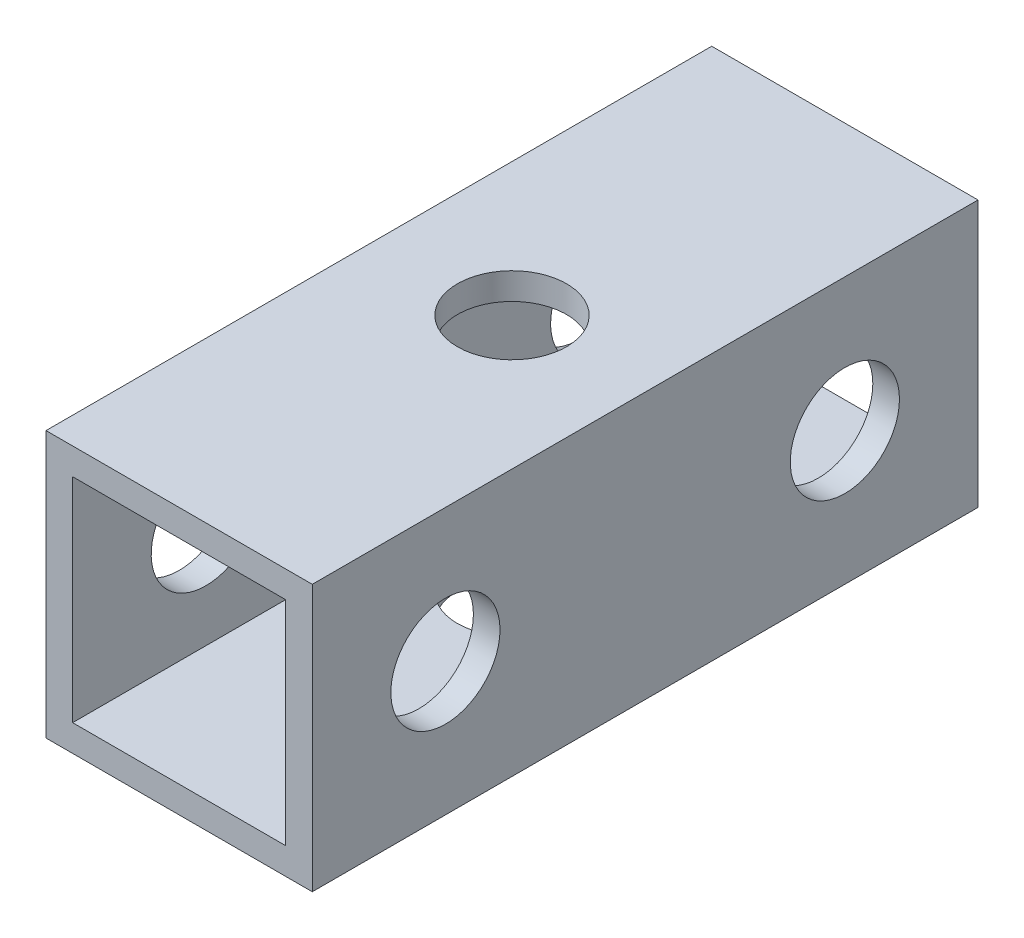
from build123d import *

# Parameters (mm, degrees)
SKETCH_1_W          = 10
SKETCH_1_H          = 10
SKETCH_1_W_2        = 8
SKETCH_1_H_2        = 8
EXTRUDE_1_DEPTH     = 12.5
SKETCH_2_R          = 2.05
CUT_EXTRUDE_1_DEPTH = 11
SKETCH_3_R          = 2.05
CUT_EXTRUDE_2_DEPTH = 11


with BuildPart() as part:
    # 草图1 → 凸台-拉伸1 (new body, symmetric)
    with BuildSketch(Plane.XY):
        Rectangle(SKETCH_1_W, SKETCH_1_H)
        Rectangle(SKETCH_1_W_2, SKETCH_1_H_2, mode=Mode.SUBTRACT)
    extrude(amount=EXTRUDE_1_DEPTH, both=True)

    # 草图2 → 切除-拉伸1 (cut, through all)
    with BuildSketch(Plane(origin=(0, 5, 0), x_dir=(1, 0, 0), z_dir=(0, 1, 0))):
        Circle(SKETCH_2_R)
    extrude(amount=-CUT_EXTRUDE_1_DEPTH, mode=Mode.SUBTRACT)

    # 草图3 → 切除-拉伸2 (cut, through all)
    with BuildSketch(Plane(origin=(5, 0, 0), x_dir=(0, 0, -1), z_dir=(1, 0, 0))):
        with Locations((-7.5, 0)):
            Circle(SKETCH_3_R)
        with Locations((7.5, 0)):
            Circle(SKETCH_3_R)
    extrude(amount=-CUT_EXTRUDE_2_DEPTH, mode=Mode.SUBTRACT)


solid = part.part
